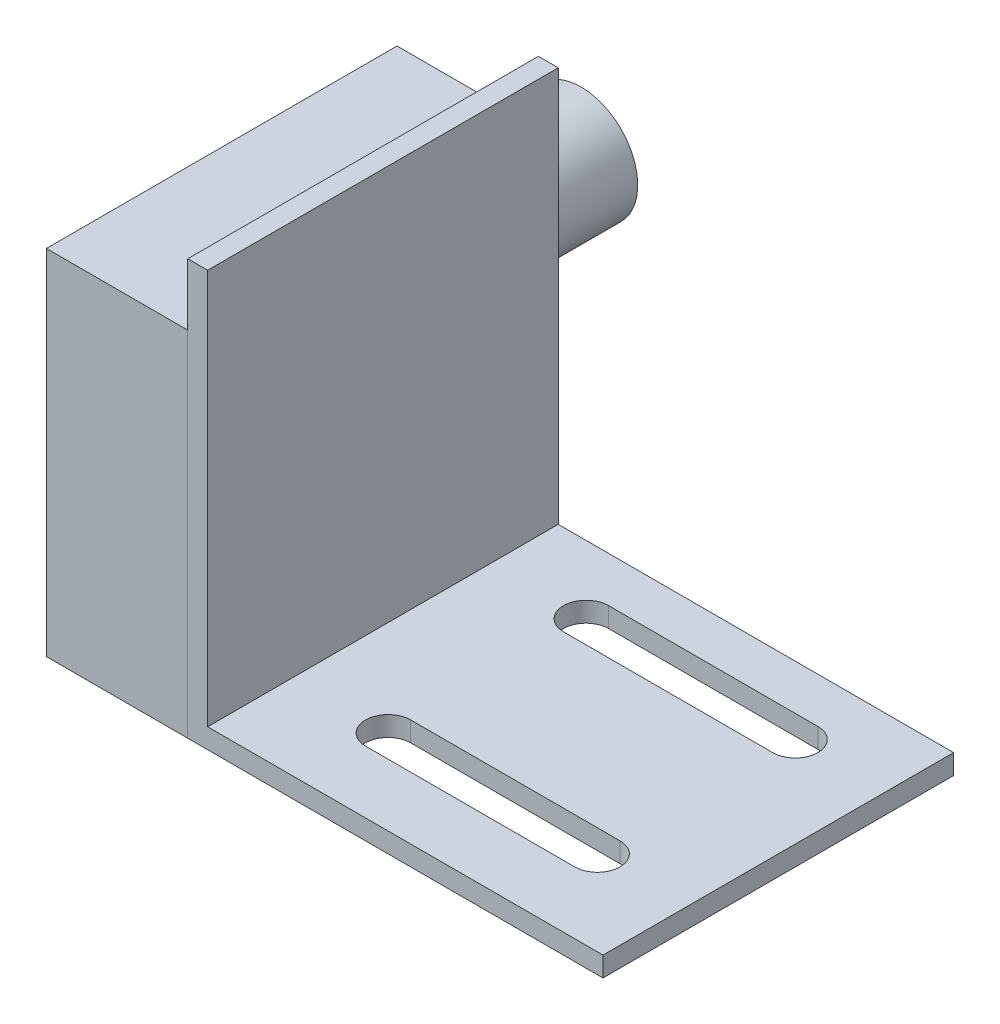
from build123d import *

# Parameters (mm, degrees)
BOSS_EXTRUDE1_DEPTH = 15.748
SKETCH2_W           = 31.496
SKETCH2_H           = 31.75
BOSS_EXTRUDE2_DEPTH = 12.7
SKETCH4_R           = 5.08
BOSS_EXTRUDE3_DEPTH = 10.16
CUT_EXTRUDE1_DEPTH  = 2.784907768
LPATTERN1_COUNT     = 2
LPATTERN1_PITCH     = 17.78


with BuildPart() as part:
    # Sketch1 → Boss-Extrude1 (new body, symmetric)
    with BuildSketch(Plane.XY):
        Polygon((0, 0), (0, 37.298312705), (1.784907768, 37.298312705), (1.784907768, 1.784907768), (37.298312705, 1.784907768), (37.298312705, 0), align=None)
    extrude(amount=BOSS_EXTRUDE1_DEPTH, both=True)

    # Sketch6 → Cut-Extrude1 (cut, through all)
    with BuildSketch(Plane(origin=(0, 1.784907768, 0), x_dir=(1, 0, 0), z_dir=(0, 1, 0))):
        with BuildLine():
            Line((29.170312705, 11.684), (10.374312705, 11.684))
            ThreePointArc((10.374312705, 11.684), (8.342312705, 9.652), (10.374312705, 7.62))
            Line((10.374312705, 7.62), (29.170312705, 7.62))
            ThreePointArc((29.170312705, 7.62), (31.202312705, 9.652), (29.170312705, 11.684))
        make_face()
    cut_extrude1 = extrude(amount=-CUT_EXTRUDE1_DEPTH, mode=Mode.SUBTRACT)

    # LPattern1: Cut-Extrude1 ×2
    with Locations(*[(0, 0, i * LPATTERN1_PITCH) for i in range(1, LPATTERN1_COUNT)]):
        add(cut_extrude1, mode=Mode.SUBTRACT)


with BuildPart() as body_2:
    # Sketch2 → Boss-Extrude2 (new body)
    with BuildSketch(Plane.ZY):
        with Locations((0, 15.875)):
            Rectangle(SKETCH2_W, SKETCH2_H)
    extrude(amount=BOSS_EXTRUDE2_DEPTH)

    # Sketch4 → Boss-Extrude3 (add)
    with BuildSketch(Plane(origin=(0, 0, -15.748), x_dir=(-1, 0, 0), z_dir=(0, 0, -1))):
        with Locations((6.320909995, 21.59)):
            Circle(SKETCH4_R)
    extrude(amount=BOSS_EXTRUDE3_DEPTH)


solid = Compound([part.part, body_2.part])
